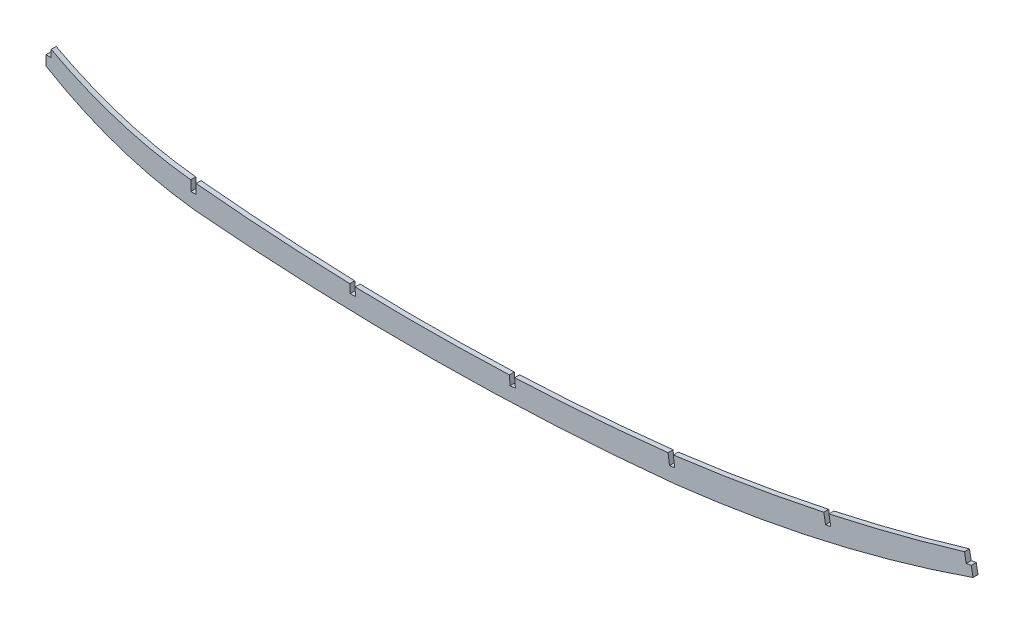
from build123d import *

# Parameters (mm, degrees)
BOSS_EXTRUDE1_DEPTH = 3.175
SKETCH3_W           = 3.3782
SKETCH3_H           = 9.116578424
CUT_EXTRUDE2_DEPTH  = 4.175


with BuildPart() as part:
    # Sketch2 → Boss-Extrude1 (new body)
    with BuildSketch(Plane.XY):
        with BuildLine():
            Line((0, -94.469447024), (0, -81.769447024))
            ThreePointArc((0, -81.769447024), (45.478698707, -101.330055673), (93.98, -111.257453101))
            ThreePointArc((93.98, -111.257453101), (246.131127604, -118.387559898), (398.184073829, -109.403930433))
            ThreePointArc((398.184073829, -109.403930433), (494.24795915, -93.166461028), (588.593285498, -68.858337449))
            Line((588.593285498, -68.858337449), (590.864339182, -81.353629169))
            ThreePointArc((590.864339182, -81.353629169), (496.73811025, -108.348158667), (400.203586987, -124.765753327))
            ThreePointArc((400.203586987, -124.765753327), (247.132802315, -132.883361709), (93.98, -126.497453101))
            ThreePointArc((93.98, -126.497453101), (45.293757409, -115.460746442), (0, -94.469447024))
        make_face()
    extrude(amount=BOSS_EXTRUDE1_DEPTH)

    # Sketch3 → Cut-Extrude2 (cut, through all)
    with BuildSketch(Plane.XY.offset(3.175)):
        Polygon((0, -81.823651503), (0, -88.181271503), (3.302, -88.181271503), (3.302, -81.823651503), (3.302, -80.849253243), (0, -80.849253243), align=None)
        with Locations((93.98, -112.972963904)):
            Rectangle(SKETCH3_W, SKETCH3_H)
        Polygon((183.426070396, 128.229599916), (183.158711139, 134.615096468), (186.330931782, 134.747916609), (186.598291039, 128.362420058), align=None)
        Polygon((193.849633474, -123.151114373), (197.224876239, -123.009793743), (196.926348208, -115.879875231), (193.551105443, -116.021195861), align=None)
        Polygon((397.375099539, -116.299780406), (400.723885221, -115.854954941), (399.211318768, -104.467880056), (395.862533086, -104.912705522), align=None)
        Polygon((295.823280702, -123.008827736), (299.189034058, -122.719104443), (298.52739573, -115.032765525), (295.161642374, -115.322488818), align=None)
        Polygon((586.515324681, -75.768921214), (589.838721446, -75.162893837), (588.533193274, -68.003500927), (585.209796509, -68.609528304), align=None)
        Polygon((496.875793957, -99.221011682), (500.199190722, -98.614984306), (498.73195058, -90.568778264), (495.408553815, -91.174805641), align=None)
    extrude(amount=-CUT_EXTRUDE2_DEPTH, mode=Mode.SUBTRACT)


solid = part.part
